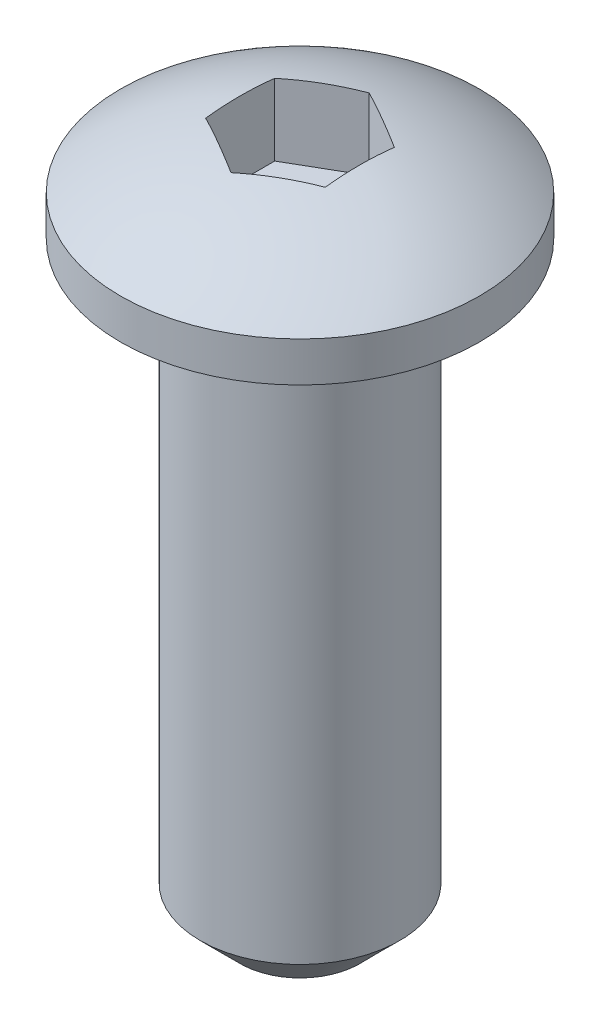
from build123d import *

# Parameters (mm, degrees)
ENL_V_START             = 0.5
ENL_V_MAT_EXTRU_1_DEPTH = 3
CHANFREIN1_SIZE         = 1


with BuildPart() as part:
    # Esquisse1 → Révolution1 (revolve)
    with BuildSketch(Plane.XY, mode=Mode.PRIVATE) as r_volution1_sk:
        with BuildLine():
            Line((0, -15), (0, 2.5))
            ThreePointArc((0, 2.5), (-2.371708245, 2.115124735), (-4.5, 1))
            Line((-4.5, 1), (-4.5, 0))
            Line((-4.5, 0), (-2.5, 0))
            Line((-2.5, 0), (-2.5, -15))
            Line((-2.5, -15), (0, -15))
        make_face()
    revolve(r_volution1_sk.sketch.rotate(Axis((0, 16.1829806, 0), (0, -1, 0)), 270), axis=Axis((0, 16.1829806, 0), (0, -1, 0)))  # turned: the seam where the file's is

    # Esquisse2 → Enlèv. mat.-Extru.1 (cut, through all)
    with BuildSketch(Plane(origin=(0, 0, 0), x_dir=(1, 0, 0), z_dir=(0, 1, 0)).offset(ENL_V_START)):
        Polygon((0, 1.732050808), (-1.5, 0.866025404), (-1.5, -0.866025404), (0, -1.732050808), (1.5, -0.866025404), (1.5, 0.866025404), align=None)
    extrude(amount=ENL_V_MAT_EXTRU_1_DEPTH, mode=Mode.SUBTRACT)

    # Chanfrein1
    chanfrein1_edges = [part.edges().sort_by_distance(p)[0] for p in [
        (0, -15, -2.5),
    ]]
    chamfer(chanfrein1_edges, length=CHANFREIN1_SIZE)


solid = part.part
